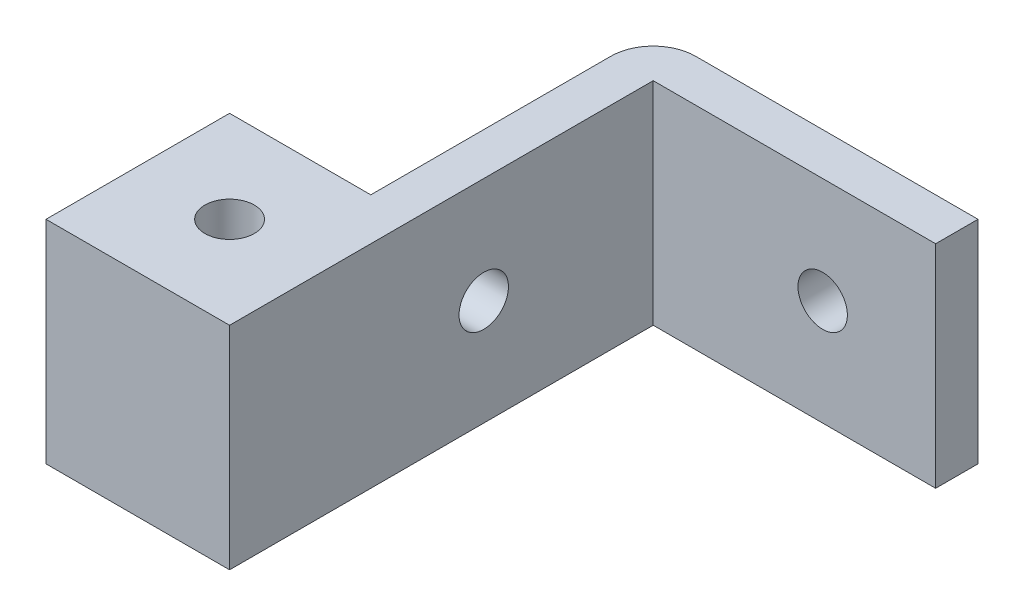
from build123d import *

# Parameters (mm, degrees)
SKETCH1_W           = 23
SKETCH1_H           = 15
BOSS_EXTRUDE1_DEPTH = 3
SKETCH10_W          = 3
SKETCH10_H          = 15
BOSS_EXTRUDE2_DEPTH = 20
SKETCH13_R          = 1.75
CUT_EXTRUDE3_DEPTH  = 24
SKETCH14_R          = 1.75
CUT_EXTRUDE4_DEPTH  = 24
FILLET1_R           = 3
SKETCH15_W          = 3
SKETCH15_H          = 15
BOSS_EXTRUDE3_DEPTH = 10
SKETCH16_W          = 13
SKETCH16_H          = 15
BOSS_EXTRUDE4_DEPTH = 10
SKETCH17_R          = 1.75
CUT_EXTRUDE5_DEPTH  = 16


with BuildPart() as part:
    # Sketch1 → Boss-Extrude1 (new body)
    with BuildSketch(Plane.XY):
        Rectangle(SKETCH1_W, SKETCH1_H)
    extrude(amount=BOSS_EXTRUDE1_DEPTH)

    # Sketch10 → Boss-Extrude2 (add)
    with BuildSketch(Plane.XY.offset(3)):
        with Locations((-10, 0)):
            Rectangle(SKETCH10_W, SKETCH10_H)
    extrude(amount=BOSS_EXTRUDE2_DEPTH)

    # Sketch13 → Cut-Extrude3 (cut, through all)
    with BuildSketch(Plane(origin=(0, 0, 0), x_dir=(-1, 0, 0), z_dir=(0, 0, -1))):
        with Locations((-3.5, 0)):
            Circle(SKETCH13_R)
    extrude(amount=-CUT_EXTRUDE3_DEPTH, mode=Mode.SUBTRACT)

    # Sketch14 → Cut-Extrude4 (cut, through all)
    with BuildSketch(Plane.ZY.offset(11.5)):
        with Locations((15, 0)):
            Circle(SKETCH14_R)
    extrude(amount=-CUT_EXTRUDE4_DEPTH, mode=Mode.SUBTRACT)

    # Fillet1
    fillet1_edges = [part.edges().sort_by_distance(p)[0] for p in [
        (-11.5, 0, 0),
    ]]
    fillet(fillet1_edges, radius=FILLET1_R)

    # Sketch15 → Boss-Extrude3 (add)
    with BuildSketch(Plane.XY.offset(23)):
        with Locations((-10, 0)):
            Rectangle(SKETCH15_W, SKETCH15_H)
    extrude(amount=BOSS_EXTRUDE3_DEPTH)

    # Sketch16 → Boss-Extrude4 (add)
    with BuildSketch(Plane.ZY.offset(11.5)):
        with Locations((26.5, 0)):
            Rectangle(SKETCH16_W, SKETCH16_H)
    extrude(amount=BOSS_EXTRUDE4_DEPTH)

    # Sketch17 → Cut-Extrude5 (cut, through all)
    with BuildSketch(Plane.XZ.offset(7.5)):
        with Locations((-15, 26.5)):
            Circle(SKETCH17_R)
    extrude(amount=-CUT_EXTRUDE5_DEPTH, mode=Mode.SUBTRACT)


solid = part.part
